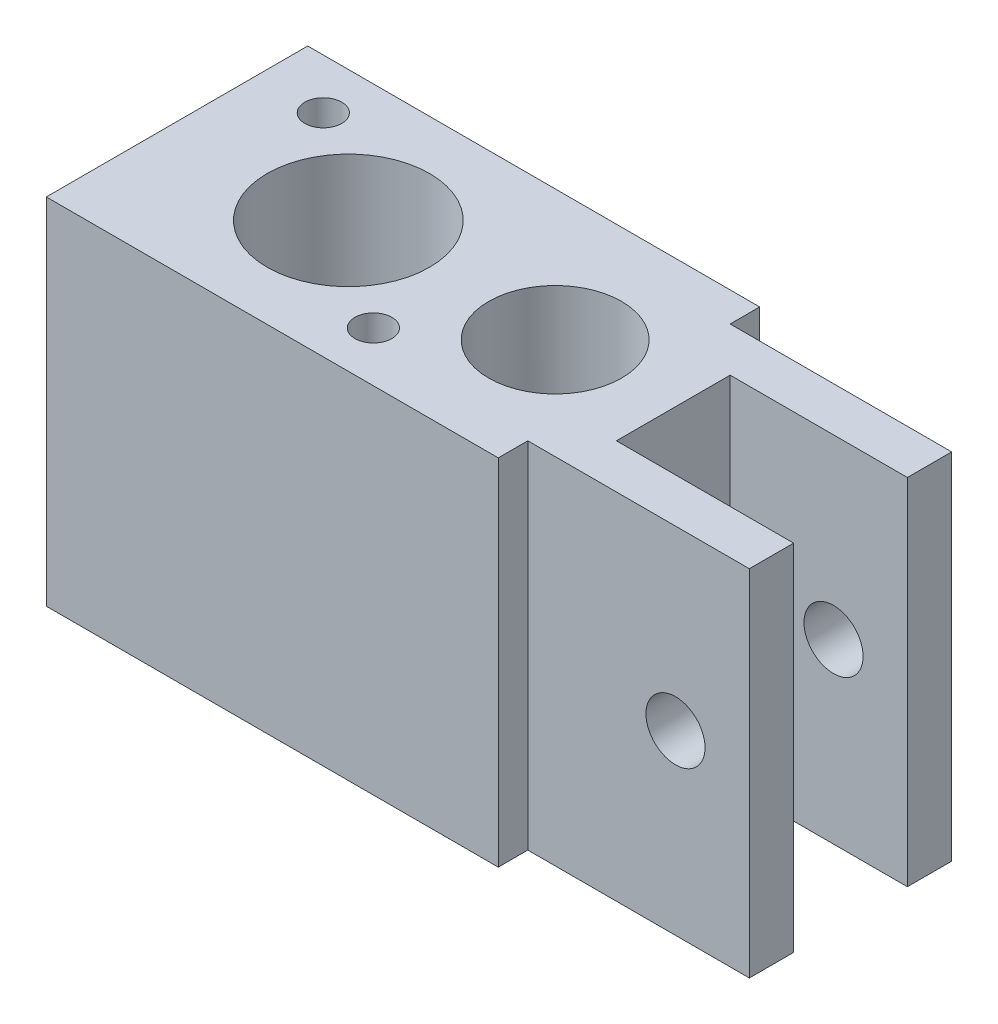
from build123d import *

# Parameters (mm, degrees)
SKIZZE3_R                            = 5.5
SKIZZE3_R_2                          = 4.5
AUFSATZ_LINEAR_AUSTRAGEN1_DEPTH      = 578.1
SKIZZE5_OUTSIDE_W                    = 164.65
SKIZZE5_OUTSIDE_H                    = 696.15
SKIZZE5_OUTSIDE_W_2                  = 45.6
SKIZZE5_OUTSIDE_H_2                  = 24
SKIZZE5_OUTSIDE_R                    = 2
SCHNITT_LINEAR_AUSTRAGEN2_DEPTH      = 9.85
SCHNITT_LINEAR_AUSTRAGEN2_DEPTH_BACK = 9.85
SKETCH2_R                            = 1.25
CUT_EXTRUDE1_DEPTH                   = 6


with BuildPart() as part:
    # Skizze3 → Aufsatz-Linear austragen1 (new body)
    with BuildSketch(Plane(origin=(0, 0, 0), x_dir=(1, 0, 0), z_dir=(0, 1, 0))):
        Polygon((-12.6, -8.85), (-12.6, 8.85), (19, 8.85), (19, 6.85), (34, 6.85), (34, 3.85), (22, 3.85), (22, -3.85), (34, -3.85), (34, -6.85), (19, -6.85), (19, -8.85), align=None)
        Circle(SKIZZE3_R, mode=Mode.SUBTRACT)
        with Locations((14, 0)):
            Circle(SKIZZE3_R_2, mode=Mode.SUBTRACT)
    extrude(amount=AUFSATZ_LINEAR_AUSTRAGEN1_DEPTH)

    # Skizze5 outside → Schnitt-Linear austragen2 (cut, two sides)
    with BuildSketch(Plane.XY) as schnitt_linear_austragen2_sk:
        with Locations((10.7, 289.05)):
            Rectangle(SKIZZE5_OUTSIDE_W, SKIZZE5_OUTSIDE_H)
        with Locations((11.2, 566.1)):
            Rectangle(SKIZZE5_OUTSIDE_W_2, SKIZZE5_OUTSIDE_H_2, mode=Mode.SUBTRACT)
        with Locations((29, 566.1)):
            Circle(SKIZZE5_OUTSIDE_R)
    extrude(amount=SCHNITT_LINEAR_AUSTRAGEN2_DEPTH, mode=Mode.SUBTRACT)
    extrude(schnitt_linear_austragen2_sk.sketch, amount=-SCHNITT_LINEAR_AUSTRAGEN2_DEPTH_BACK, mode=Mode.SUBTRACT)

    # Sketch2 → Cut-Extrude1 (cut)
    with BuildSketch(Plane(origin=(0, 578.1, 0), x_dir=(1, 0, 0), z_dir=(0, 1, 0))):
        with Locations((-7.155344001, 5.459034001)):
            Circle(SKETCH2_R)
        with Locations((7.155344001, -5.459034001)):
            Circle(SKETCH2_R)
    extrude(amount=-CUT_EXTRUDE1_DEPTH, mode=Mode.SUBTRACT)


solid = part.part
